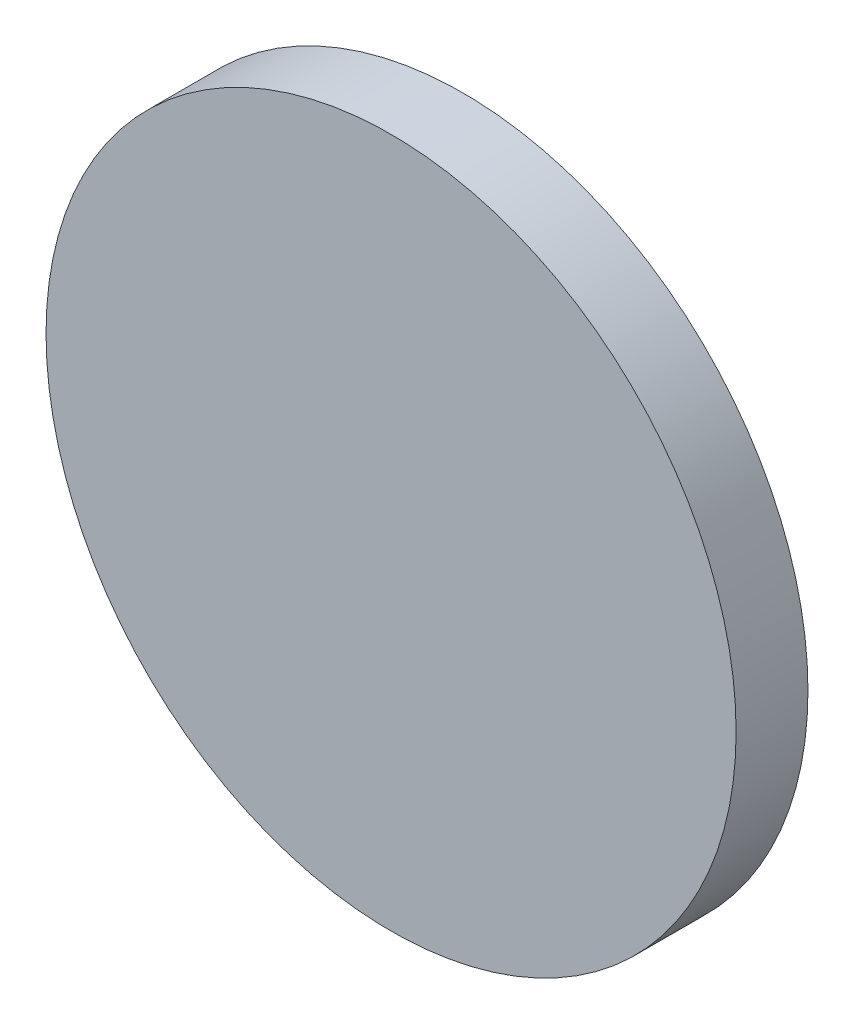
from build123d import *

# Parameters (mm, degrees)
SKETCH1_R           = 42.5
BOSS_EXTRUDE1_DEPTH = 8.85


with BuildPart() as part:
    # Sketch1 → Boss-Extrude1 (new body)
    with BuildSketch(Plane.XY):
        Circle(SKETCH1_R)
    extrude(amount=BOSS_EXTRUDE1_DEPTH)


solid = part.part
